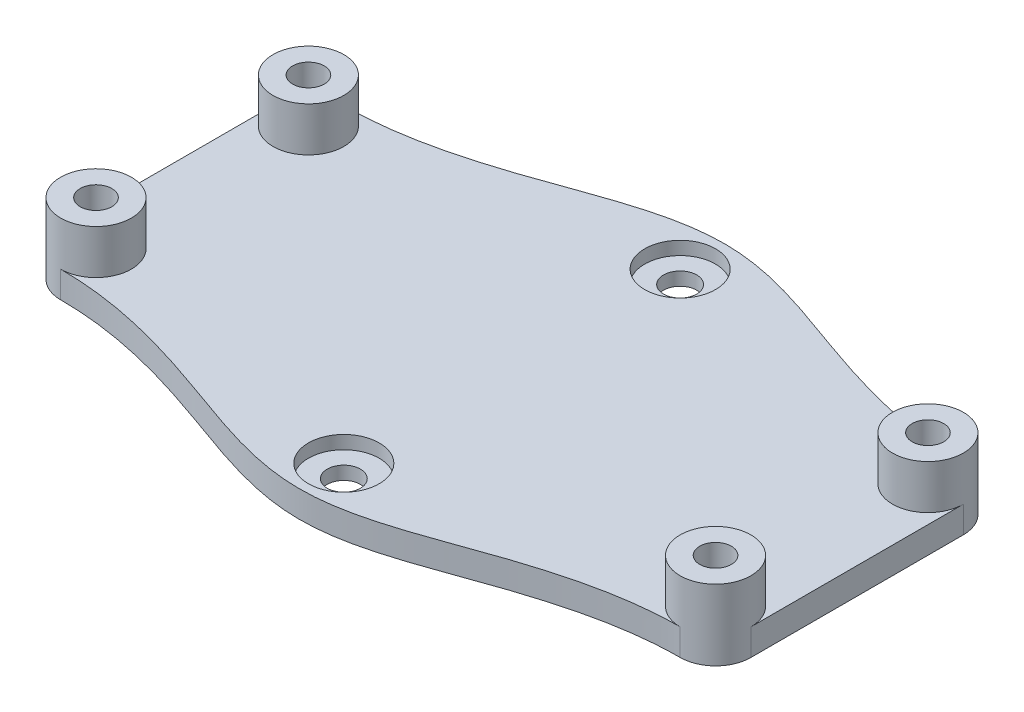
from build123d import *

# Parameters (mm, degrees)
BOSS_EXTRUDE3_DEPTH = 3
SKETCH13_R          = 4
SKETCH13_R_2        = 1.7859375
BOSS_EXTRUDE4_DEPTH = 5
SKETCH14_R          = 4
CUT_EXTRUDE8_DEPTH  = 1.5
SKETCH15_R          = 1.875
CUT_EXTRUDE9_DEPTH  = 4.0000001


with BuildPart() as part:
    # Sketch11 → Boss-Extrude3 (new body)
    with BuildSketch(Plane(origin=(0, 0, 0), x_dir=(1, 0, 0), z_dir=(0, 1, 0))):
        with BuildLine():
            Line((37.748131547, 6.010178191), (37.748131547, -17.989821809))
            ThreePointArc((37.748131547, -17.989821809), (36.576558672, -20.818248934), (33.748131547, -21.989821809))
            add(Edge.make_bspline(
                [(-36.251868453, -21.989821809), (-30.327598806, -21.989821809), (-19.243874055, -24.873158899), (-7.077839403, -30.012200103), (4.574088551, -30.012200103), (16.743326023, -24.873158899), (27.816510145, -21.989821809), (33.748131547, -21.989821809)],
                knots=[0, 0, 0, 0, 0.248449553, 0.474844955, 0.525155045, 0.751550447, 1, 1, 1, 1], degree=3))
            ThreePointArc((-36.251868453, -21.989821809), (-39.080295577, -20.818248934), (-40.251868453, -17.989821809))
            Line((-40.251868453, -17.989821809), (-40.251868453, 6.010178191))
            ThreePointArc((-40.251868453, 6.010178191), (-39.080295577, 8.838605316), (-36.251868453, 10.010178191))
            add(Edge.make_bspline(
                [(-36.251868453, 10.010178191), (-30.320247051, 10.010178191), (-19.247062928, 12.893515281), (-7.077825456, 18.032556484), (4.574102497, 18.032556484), (16.74013715, 12.893515281), (27.8238619, 10.010178191), (33.748131547, 10.010178191)],
                knots=[0, 0, 0, 0, 0.248449553, 0.474844955, 0.525155045, 0.751550447, 1, 1, 1, 1], degree=3))
            ThreePointArc((33.748131547, 10.010178191), (36.576558672, 8.838605316), (37.748131547, 6.010178191))
        make_face()
    extrude(amount=-BOSS_EXTRUDE3_DEPTH)

    # Sketch13 → Boss-Extrude4 (add)
    with BuildSketch(Plane(origin=(0, 0, 0), x_dir=(1, 0, 0), z_dir=(0, 1, 0))):
        with Locations(Location((-36.251868453, -17.989821809, 0), (0, 0, 270))):  # turned: the seam where the file's is
            Circle(SKETCH13_R)
        with Locations(Location((-36.251868453, -17.989821809, 0), (0, 0, 270))):  # turned: the seam where the file's is
            Circle(SKETCH13_R_2, mode=Mode.SUBTRACT)
        with Locations(Location((-36.251868453, 6.010178191, 0), (0, 0, 270))):  # turned: the seam where the file's is
            Circle(SKETCH13_R)
        with Locations(Location((-36.251868453, 6.010178191, 0), (0, 0, 270))):  # turned: the seam where the file's is
            Circle(SKETCH13_R_2, mode=Mode.SUBTRACT)
        with Locations(Location((33.748131547, 6.010178191, 0), (0, 0, 270))):  # turned: the seam where the file's is
            Circle(SKETCH13_R)
        with Locations(Location((33.748131547, 6.010178191, 0), (0, 0, 270))):  # turned: the seam where the file's is
            Circle(SKETCH13_R_2, mode=Mode.SUBTRACT)
        with Locations(Location((33.748131547, -17.989821809, 0), (0, 0, 270))):  # turned: the seam where the file's is
            Circle(SKETCH13_R)
        with Locations(Location((33.748131547, -17.989821809, 0), (0, 0, 270))):  # turned: the seam where the file's is
            Circle(SKETCH13_R_2, mode=Mode.SUBTRACT)
    extrude(amount=BOSS_EXTRUDE4_DEPTH)

    # Sketch14 → Cut-Extrude8 (cut)
    with BuildSketch(Plane(origin=(0, 0, 0), x_dir=(1, 0, 0), z_dir=(0, 1, 0))):
        with Locations(Location((-1.251868453, 13.010178191, 0), (0, 0, 270))):  # turned: the seam where the file's is
            Circle(SKETCH14_R)
        with Locations(Location((-1.251868453, -24.989821809, 0), (0, 0, 270))):  # turned: the seam where the file's is
            Circle(SKETCH14_R)
    extrude(amount=-CUT_EXTRUDE8_DEPTH, mode=Mode.SUBTRACT)

    # Sketch15 → Cut-Extrude9 (cut, through all)
    with BuildSketch(Plane(origin=(0, 0, 0), x_dir=(1, 0, 0), z_dir=(0, 1, 0))):
        with Locations(Location((-1.251868453, -24.989821809, 0), (0, 0, 270))):  # turned: the seam where the file's is
            Circle(SKETCH15_R)
        with Locations(Location((-1.251868453, 13.010178191, 0), (0, 0, 270))):  # turned: the seam where the file's is
            Circle(SKETCH15_R)
    extrude(amount=-CUT_EXTRUDE9_DEPTH, mode=Mode.SUBTRACT)


solid = part.part
